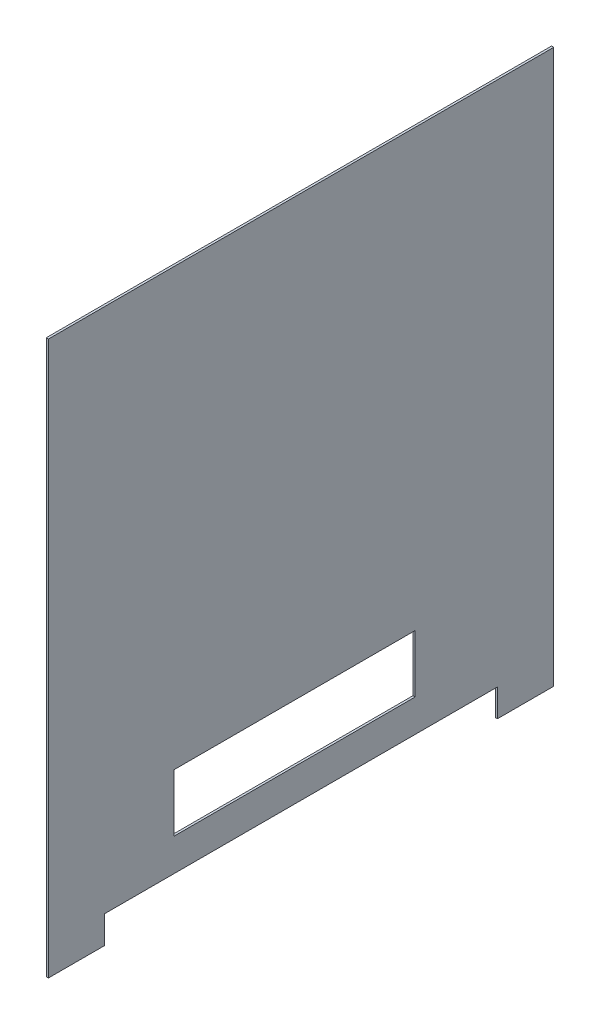
from build123d import *

# Parameters (mm, degrees)
SKETCH1_W           = 458
SKETCH1_H           = 476.6
BOSS_EXTRUDE1_DEPTH = 2
SKETCH2_W           = 51
SKETCH2_H           = 25
BOSS_EXTRUDE2_DEPTH = 2
SKETCH3_W           = 218.693705359
SKETCH3_H           = 52.165471003
CUT_EXTRUDE1_DEPTH  = 10


with BuildPart() as part:
    # Sketch1 → Boss-Extrude1 (new body)
    with BuildSketch(Plane(origin=(0, 0, 0), x_dir=(0, 0, -1), z_dir=(1, 0, 0))):
        with Locations((55.806722689, -22.770588235)):
            Rectangle(SKETCH1_W, SKETCH1_H)
    extrude(amount=BOSS_EXTRUDE1_DEPTH)

    # Sketch2 → Boss-Extrude2 (add)
    with BuildSketch(Plane(origin=(2, 0, 0), x_dir=(0, 0, -1), z_dir=(1, 0, 0))):
        with Locations((-147.693277311, -273.570588235)):
            Rectangle(SKETCH2_W, SKETCH2_H)
        with Locations((259.306722689, -273.570588235)):
            Rectangle(SKETCH2_W, SKETCH2_H)
    extrude(amount=-BOSS_EXTRUDE2_DEPTH)

    # Sketch3 → Cut-Extrude1 (cut)
    with BuildSketch(Plane.ZY):
        with Locations((-49.796656363, -205.571162235)):
            Rectangle(SKETCH3_W, SKETCH3_H)
    extrude(amount=-CUT_EXTRUDE1_DEPTH, mode=Mode.SUBTRACT)


solid = part.part
